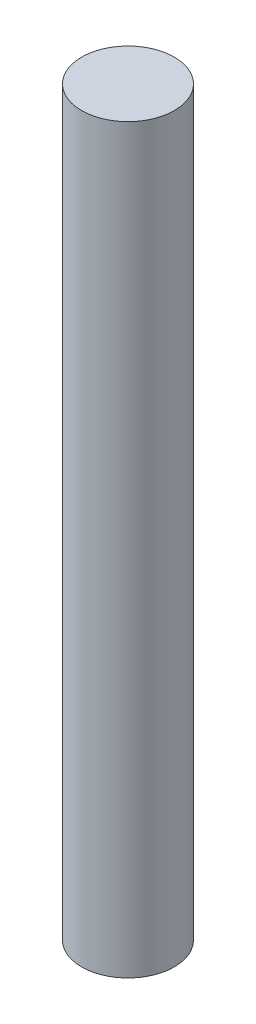
from build123d import *

# Parameters (mm, degrees)
SKETCH1_R           = 4.7625
BOSS_EXTRUDE1_DEPTH = 38.1
SKETCH2_R           = 3.175
CUT_EXTRUDE1_DEPTH  = 6.35


with BuildPart() as part:
    # Sketch1 → Boss-Extrude1 (new body, symmetric)
    with BuildSketch(Plane(origin=(0, 0, 0), x_dir=(1, 0, 0), z_dir=(0, 1, 0))):
        Circle(SKETCH1_R)
    extrude(amount=BOSS_EXTRUDE1_DEPTH, both=True)

    # Sketch2 → Cut-Extrude1 (cut)
    with BuildSketch(Plane.XZ.offset(38.1)):
        Circle(SKETCH2_R)
    extrude(amount=-CUT_EXTRUDE1_DEPTH, mode=Mode.SUBTRACT)


solid = part.part
